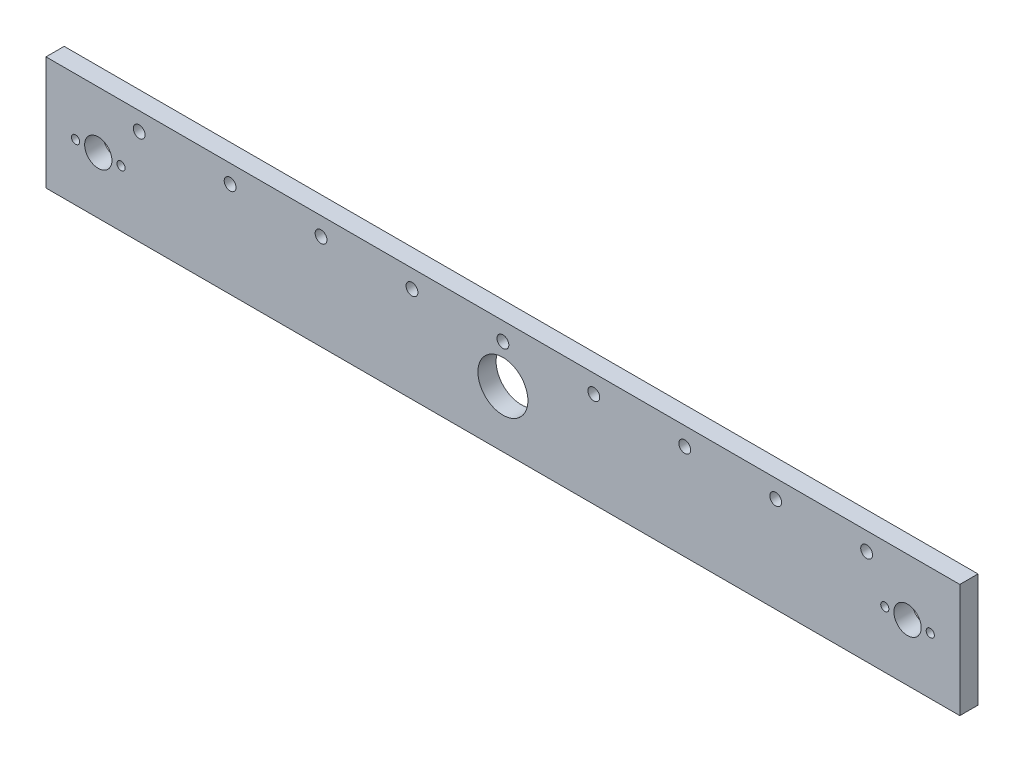
from build123d import *

# Parameters (mm, degrees)
SKETCH1_W           = 402
SKETCH1_H           = 50
SKETCH1_R           = 6
SKETCH1_R_2         = 1.8
SKETCH1_R_3         = 11
SKETCH1_R_4         = 2.6
BOSS_EXTRUDE1_DEPTH = 8


with BuildPart() as part:
    # Sketch1 → Boss-Extrude1 (new body)
    with BuildSketch(Plane.XY):
        Rectangle(SKETCH1_W, SKETCH1_H)
        with Locations((-178, 0)):
            Circle(SKETCH1_R, mode=Mode.SUBTRACT)
        with Locations((168, 0)):
            Circle(SKETCH1_R_2, mode=Mode.SUBTRACT)
        Circle(SKETCH1_R_3, mode=Mode.SUBTRACT)
        with Locations((-188, 0)):
            Circle(SKETCH1_R_2, mode=Mode.SUBTRACT)
        with Locations((-168, 0)):
            Circle(SKETCH1_R_2, mode=Mode.SUBTRACT)
        with Locations((188, 0)):
            Circle(SKETCH1_R_2, mode=Mode.SUBTRACT)
        with Locations((178, 0)):
            Circle(SKETCH1_R, mode=Mode.SUBTRACT)
        with Locations((0, 17)):
            Circle(SKETCH1_R_4, mode=Mode.SUBTRACT)
        with Locations((-40, 17)):
            Circle(SKETCH1_R_4, mode=Mode.SUBTRACT)
        with Locations((-80, 17)):
            Circle(SKETCH1_R_4, mode=Mode.SUBTRACT)
        with Locations((-120, 17)):
            Circle(SKETCH1_R_4, mode=Mode.SUBTRACT)
        with Locations((-160, 17)):
            Circle(SKETCH1_R_4, mode=Mode.SUBTRACT)
        with Locations((40, 17)):
            Circle(SKETCH1_R_4, mode=Mode.SUBTRACT)
        with Locations((80, 17)):
            Circle(SKETCH1_R_4, mode=Mode.SUBTRACT)
        with Locations((120, 17)):
            Circle(SKETCH1_R_4, mode=Mode.SUBTRACT)
        with Locations((160, 17)):
            Circle(SKETCH1_R_4, mode=Mode.SUBTRACT)
    extrude(amount=BOSS_EXTRUDE1_DEPTH)


solid = part.part
